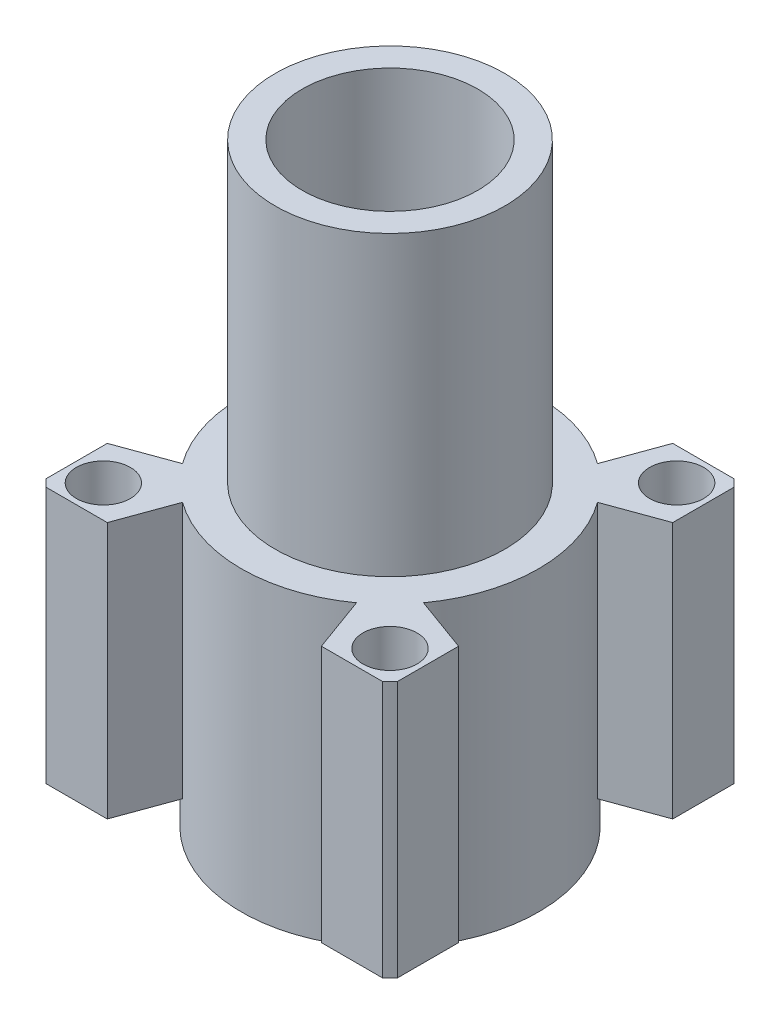
from build123d import *

# Parameters (mm, degrees)
ESQUISSE3_R      = 2
ESQUISSE3_R_2    = 10
EXTRUSION2_DEPTH = 19


with BuildPart() as part:
    # Esquisse1 → Révolution1 (revolve)
    with BuildSketch(Plane.XY):
        Polygon((-6.5, 17), (-6.5, 41), (-8.5, 41), (-8.5, 19), (-11, 19), (-11, -3), (-10, -3), (-10, 17), align=None)
    revolve(axis=Axis((0, 0, 0), (0, 1, 0)))

    # Esquisse3 → Extrusion2 (add)
    with BuildSketch(Plane(origin=(0, 19, 0), x_dir=(1, 0, 0), z_dir=(0, 1, 0))):
        with BuildLine():
            Line((-12.449899598, -13), (-7.924146363, -13))
            Line((-7.924146363, -13), (-6.438678833, -8.918711504))
            ThreePointArc((-6.438678833, -8.918711504), (0, -11), (6.438678833, -8.918711504))
            Line((6.438678833, -8.918711504), (7.924146363, -13))
            Line((7.924146363, -13), (12.449899598, -13))
            ThreePointArc((12.449899598, -13), (12.727922061, -12.727922061), (13, -12.449899598))
            Line((13, -12.449899598), (13, -7.924146363))
            Line((13, -7.924146363), (8.918711504, -6.438678833))
            ThreePointArc((8.918711504, -6.438678833), (11, 0), (8.918711504, 6.438678833))
            Line((8.918711504, 6.438678833), (13, 7.924146363))
            Line((13, 7.924146363), (13, 12.449899598))
            ThreePointArc((13, 12.449899598), (12.727922061, 12.727922061), (12.449899598, 13))
            Line((12.449899598, 13), (7.924146363, 13))
            Line((7.924146363, 13), (6.438678833, 8.918711504))
            ThreePointArc((6.438678833, 8.918711504), (0, 11), (-6.438678833, 8.918711504))
            Line((-6.438678833, 8.918711504), (-7.924146363, 13))
            Line((-7.924146363, 13), (-12.449899598, 13))
            ThreePointArc((-12.449899598, 13), (-12.727922061, 12.727922061), (-13, 12.449899598))
            Line((-13, 12.449899598), (-13, 7.924146363))
            Line((-13, 7.924146363), (-8.918711504, 6.438678833))
            ThreePointArc((-8.918711504, 6.438678833), (-11, 0), (-8.918711504, -6.438678833))
            Line((-8.918711504, -6.438678833), (-13, -7.924146363))
            Line((-13, -7.924146363), (-13, -12.449899598))
            ThreePointArc((-13, -12.449899598), (-12.727922061, -12.727922061), (-12.449899598, -13))
        make_face()
        with Locations((10.606601718, 10.606601718)):
            Circle(ESQUISSE3_R, mode=Mode.SUBTRACT)
        with Locations((-10.606601718, -10.606601718)):
            Circle(ESQUISSE3_R, mode=Mode.SUBTRACT)
        with Locations((-10.606601718, 10.606601718)):
            Circle(ESQUISSE3_R, mode=Mode.SUBTRACT)
        with Locations((10.606601718, -10.606601718)):
            Circle(ESQUISSE3_R, mode=Mode.SUBTRACT)
        Circle(ESQUISSE3_R_2, mode=Mode.SUBTRACT)
    extrude(amount=-EXTRUSION2_DEPTH)


solid = part.part
